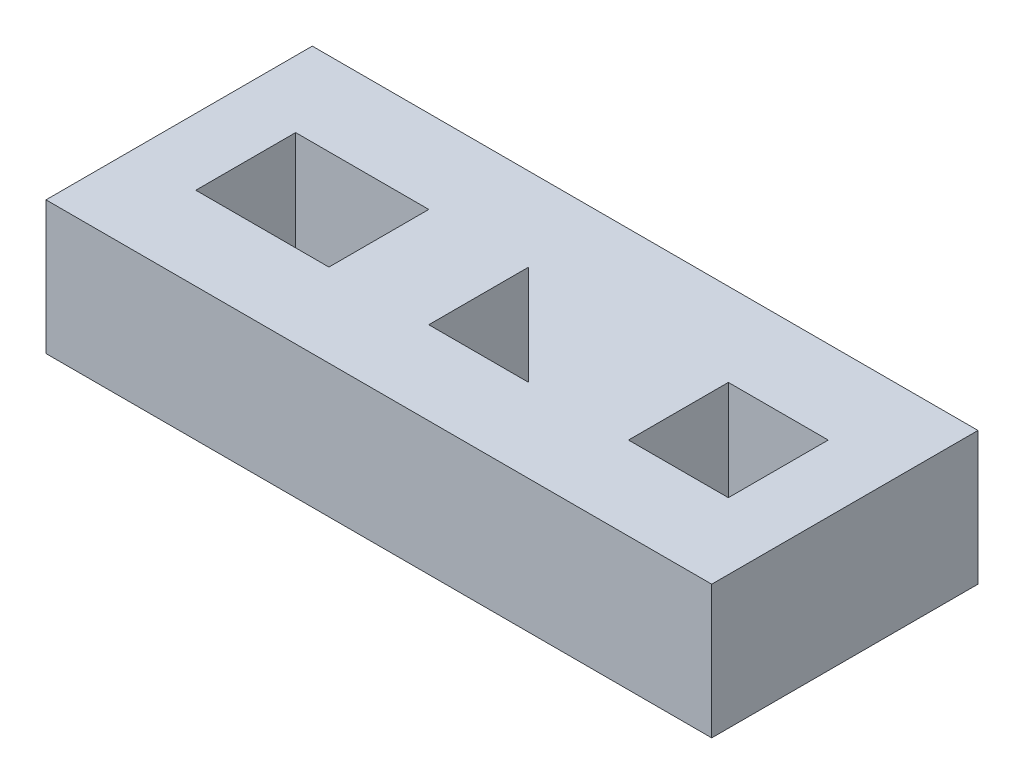
from build123d import *

# Parameters (mm, degrees)
SKETCH1_W           = 127
SKETCH1_H           = 50.8
BOSS_EXTRUDE1_DEPTH = 25.4
SKETCH2_W           = 25.4
SKETCH2_H           = 19.05
SKETCH2_W_2         = 19.05
CUT_EXTRUDE1_DEPTH  = 26.4


with BuildPart() as part:
    # Sketch1 → Boss-Extrude1 (new body)
    with BuildSketch(Plane(origin=(0, 0, 0), x_dir=(1, 0, 0), z_dir=(0, 1, 0))):
        with Locations((63.5, 25.4)):
            Rectangle(SKETCH1_W, SKETCH1_H)
    extrude(amount=BOSS_EXTRUDE1_DEPTH)

    # Sketch2 → Cut-Extrude1 (cut, through all)
    with BuildSketch(Plane(origin=(0, 25.4, 0), x_dir=(1, 0, 0), z_dir=(0, 1, 0))):
        Polygon((57.15, 34.925), (57.15, 15.875), (76.2, 15.875), align=None)
        with Locations((25.4, 25.4)):
            Rectangle(SKETCH2_W, SKETCH2_H)
        with Locations((104.775, 25.4)):
            Rectangle(SKETCH2_W_2, SKETCH2_H)
    extrude(amount=-CUT_EXTRUDE1_DEPTH, mode=Mode.SUBTRACT)


solid = part.part
